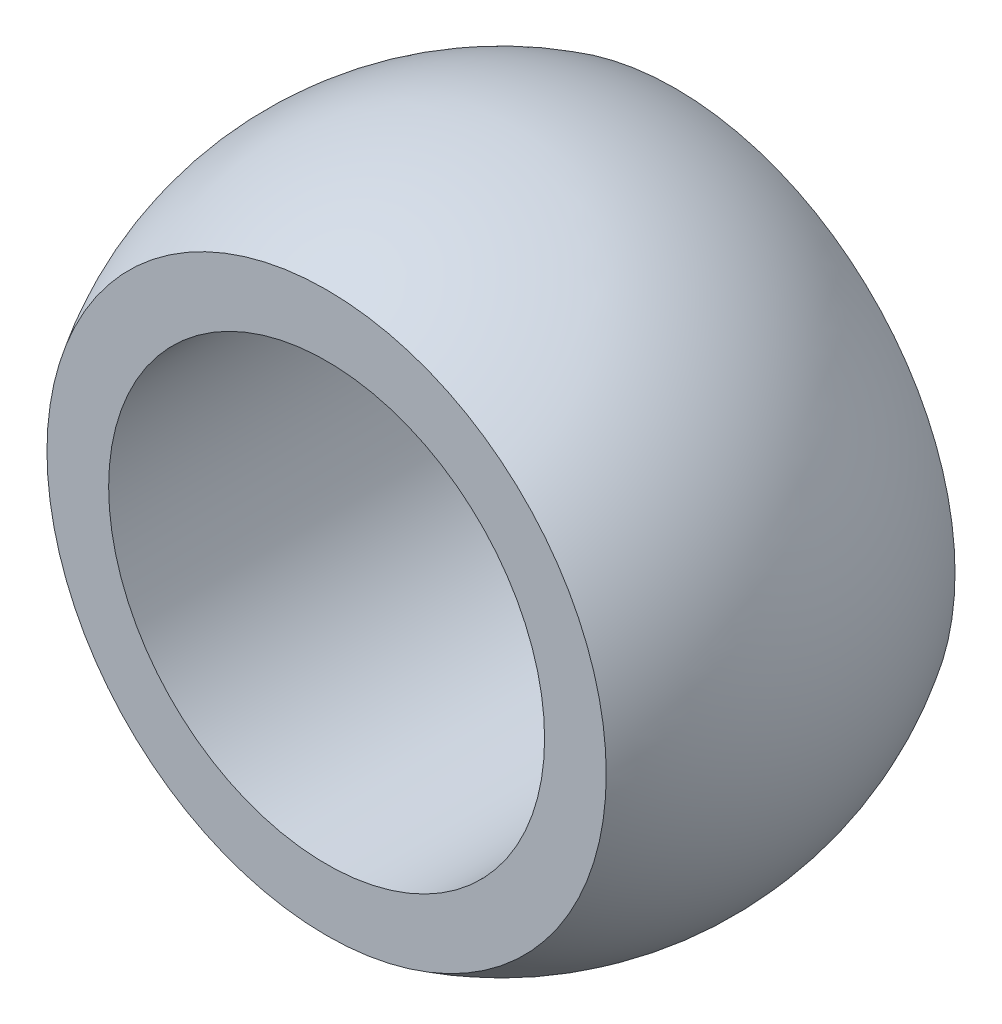
from build123d import *

# Parameters (mm, degrees)
CUT_EXTRUDE1_DEPTH      = 13.00023
CUT_EXTRUDE1_DEPTH_BACK = 13.00023
SKETCH3_R               = 7.9375
CUT_EXTRUDE3_DEPTH      = 13.7


with BuildPart() as part:
    # Sketch1 → Revolve1 (revolve)
    with BuildSketch(Plane(origin=(0, 0, 0), x_dir=(1, 0, 0), z_dir=(0, 1, 0))):
        with BuildLine():
            Line((0, 12.00023), (0, -12.00023))
            ThreePointArc((0, -12.00023), (12.00023, 0), (0, 12.00023))
        make_face()
    revolve(axis=Axis((0, 0, -16.515997735), (0, 0, 1)))

    # Sketch2 → Cut-Extrude1 (cut, two sides)
    with BuildSketch(Plane(origin=(0, 0, 0), x_dir=(0, 0, -1), z_dir=(1, 0, 0))) as cut_extrude1_sk:
        with BuildLine():
            Line((-6.35, 10.182485947), (-6.35, -10.182485947))
            ThreePointArc((-6.35, -10.182485947), (-12.00023, 0), (-6.35, 10.182485947))
        make_face()
        with BuildLine():
            ThreePointArc((6.35, -10.182485947), (12.00023, 0), (6.35, 10.182485947))
            Line((6.35, 10.182485947), (6.35, -10.182485947))
        make_face()
    extrude(amount=CUT_EXTRUDE1_DEPTH, mode=Mode.SUBTRACT)
    extrude(cut_extrude1_sk.sketch, amount=-CUT_EXTRUDE1_DEPTH_BACK, mode=Mode.SUBTRACT)

    # Sketch3 → Cut-Extrude3 (cut, through all)
    with BuildSketch(Plane.XY.offset(6.35)):
        Circle(SKETCH3_R)
    extrude(amount=-CUT_EXTRUDE3_DEPTH, mode=Mode.SUBTRACT)


solid = part.part
